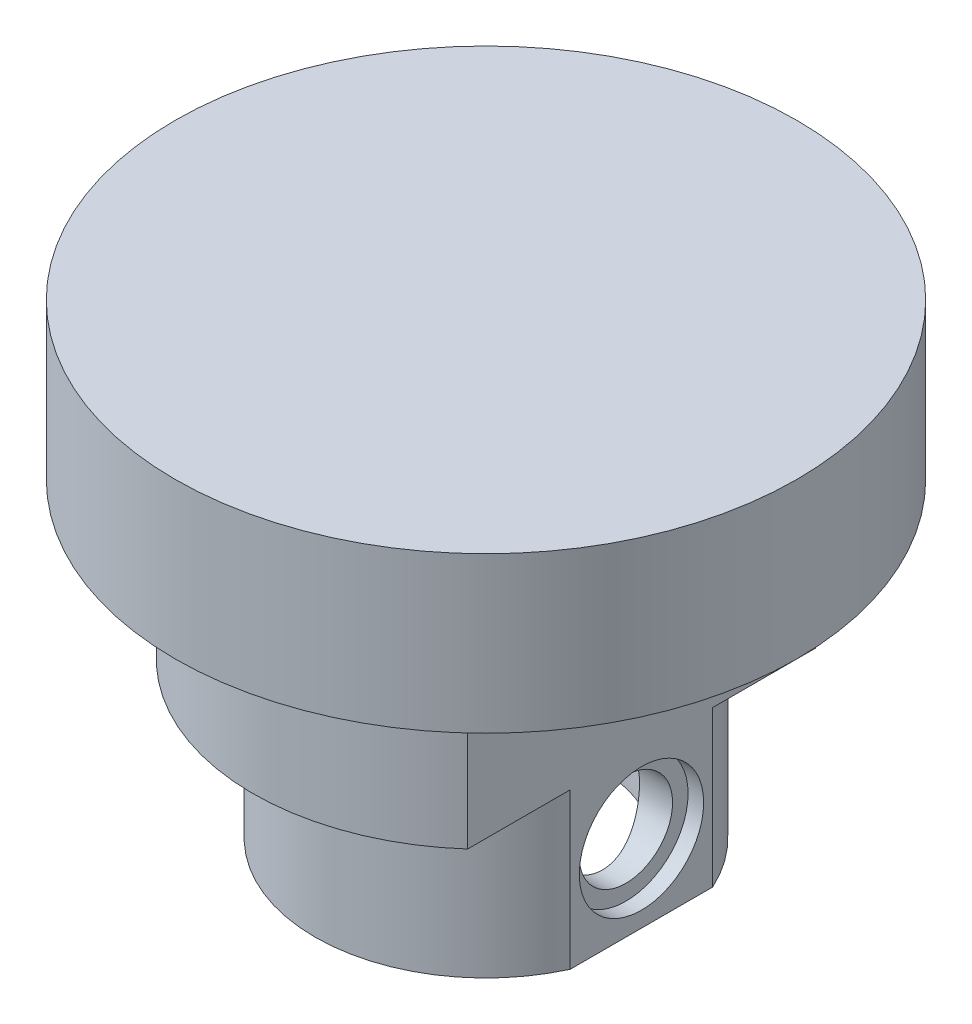
from build123d import *

# Parameters (mm, degrees)
SKETCH1_R           = 20
STOCK_DEPTH         = 20
CUT_EXTRUDE1_START  = -10
SKETCH2_OUTSIDE_W   = 54
SKETCH2_OUTSIDE_H   = 54
SKETCH2_OUTSIDE_R   = 15
CUT_EXTRUDE1_DEPTH  = 10
BOSS_EXTRUDE2_START = -20
SKETCH4_R           = 11
BOSS_EXTRUDE2_DEPTH = 10
MAINKEY_START       = -30
SKETCH3_W           = 10
SKETCH3_H           = 22.360679774
MAINKEY_DEPTH       = 20
CENTREBORE_START    = -30
SKETCH5_R           = 7.5
CENTREBORE_DEPTH    = 25
SKETCH6_R           = 3
HOLES_DEPTH         = 23.674794
SKETCH7_R           = 4
CUT_EXTRUDE4_DEPTH  = 1


with BuildPart() as part:
    # Sketch1 → Stock (new body)
    with BuildSketch(Plane(origin=(0, 0, 0), x_dir=(1, 0, 0), z_dir=(0, 1, 0))):
        Circle(SKETCH1_R)
    extrude(amount=-STOCK_DEPTH)

    # Sketch2 outside → Cut-Extrude1 (cut)
    with BuildSketch(Plane(origin=(0, 0, 0), x_dir=(1, 0, 0), z_dir=(0, 1, 0)).offset(CUT_EXTRUDE1_START)):
        Rectangle(SKETCH2_OUTSIDE_W, SKETCH2_OUTSIDE_H)
        Circle(SKETCH2_OUTSIDE_R, mode=Mode.SUBTRACT)
    extrude(amount=-CUT_EXTRUDE1_DEPTH, mode=Mode.SUBTRACT)

    # Sketch4 → Boss-Extrude2 (add)
    with BuildSketch(Plane(origin=(0, 0, 0), x_dir=(1, 0, 0), z_dir=(0, 1, 0)).offset(BOSS_EXTRUDE2_START)):
        Circle(SKETCH4_R)
    extrude(amount=-BOSS_EXTRUDE2_DEPTH)

    # Sketch3 → MainKey (cut)
    with BuildSketch(Plane(origin=(0, 0, 0), x_dir=(1, 0, 0), z_dir=(0, 1, 0)).offset(MAINKEY_START)):
        with Locations((15, 0)):
            Rectangle(SKETCH3_W, SKETCH3_H)
    extrude(amount=MAINKEY_DEPTH, mode=Mode.SUBTRACT)

    # Sketch5 → CentreBore (cut)
    with BuildSketch(Plane(origin=(0, 0, 0), x_dir=(1, 0, 0), z_dir=(0, 1, 0)).offset(CENTREBORE_START)):
        Circle(SKETCH5_R)
    extrude(amount=CENTREBORE_DEPTH, mode=Mode.SUBTRACT)

    # Sketch6 → Holes (cut)
    with BuildSketch(Plane(origin=(10, 0, 0), x_dir=(0, 0, -1), z_dir=(1, 0, 0))):
        with Locations((0, -25)):
            Circle(SKETCH6_R)
    extrude(amount=-HOLES_DEPTH, mode=Mode.SUBTRACT)

    # Sketch7 → Cut-Extrude4 (cut)
    with BuildSketch(Plane(origin=(10, 0, 0), x_dir=(0, 0, -1), z_dir=(1, 0, 0))):
        with Locations((0, -25)):
            Circle(SKETCH7_R)
    extrude(amount=-CUT_EXTRUDE4_DEPTH, mode=Mode.SUBTRACT)


solid = part.part
